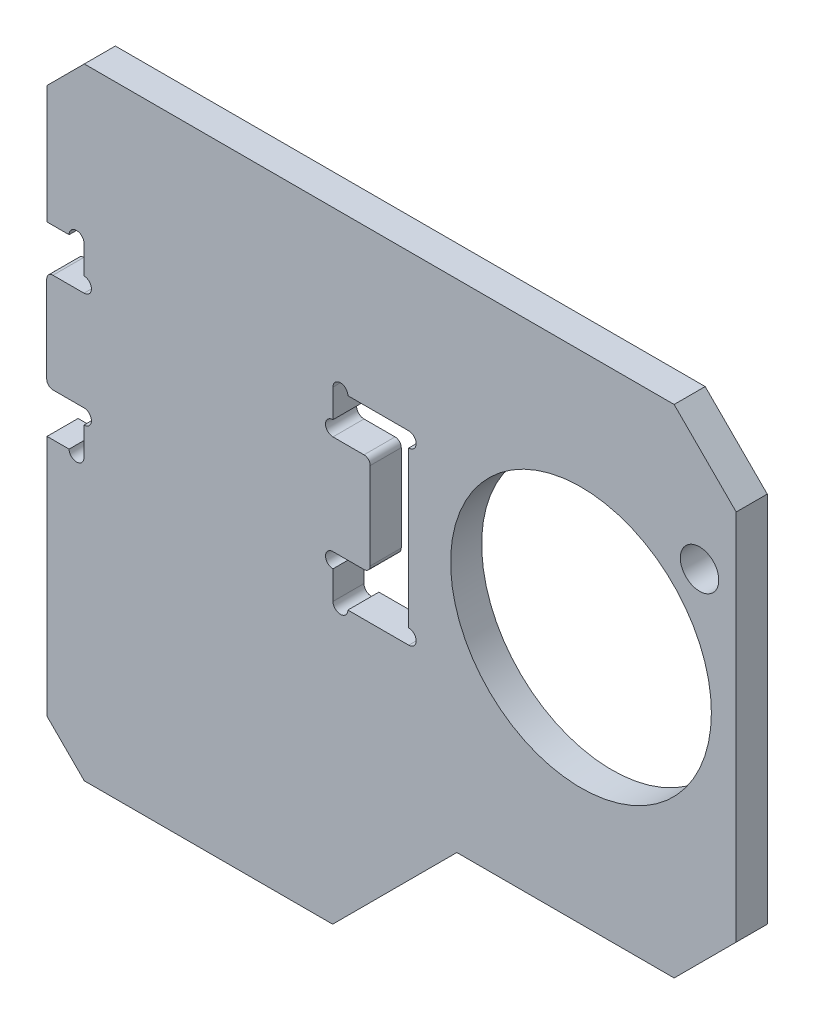
from build123d import *

# Parameters (mm, degrees)
EXTRUDE_1_DEPTH     = 1.25
SKETCH_2_R          = 0.6
CUT_EXTRUDE_1_DEPTH = 3.5
FILLET_1_R          = 0.5
SKETCH_3_R          = 10.5
CUT_EXTRUDE_2_DEPTH = 3.5
CHAMFER_1_SIZE      = 5
CHAMFER_2_SIZE      = 15
CHAMFER_3_SIZE      = 3
CUT_EXTRUDE_4_DEPTH = 3.5
SKETCH_6_R          = 1.55
CUT_EXTRUDE_5_DEPTH = 3.5


with BuildPart() as part:
    # 草图1 → 凸台-拉伸1 (new body, symmetric)
    with BuildSketch(Plane.XY):
        Polygon((-13, 20), (-13, 7.475), (-10.025, 7.475), (-10.025, 4), (-13.025, 4), (-13.025, -4), (-10.025, -4), (-10.025, -7.475), (-13, -7.475), (-13, -30), (42.5, -30), (42.5, 20), align=None)
        Polygon((10.025, 7.475), (10.025, 4), (13.025, 4), (13.025, -4), (10.025, -4), (10.025, -7.475), (16.125, -7.475), (16.125, 7.475), align=None, mode=Mode.SUBTRACT)
    extrude(amount=EXTRUDE_1_DEPTH, both=True)

    # 草图2 → 切除-拉伸1 (cut, through all)
    with BuildSketch(Plane.XY.offset(1.25)):
        with Locations((10.625, 7.475)):
            Circle(SKETCH_2_R)
        with Locations((16.125, 6.875)):
            Circle(SKETCH_2_R)
        with Locations((10.025, 4.6)):
            Circle(SKETCH_2_R)
        with Locations((10.025, -4.6)):
            Circle(SKETCH_2_R)
        with Locations((10.625, -7.475)):
            Circle(SKETCH_2_R)
        with Locations((16.125, -6.875)):
            Circle(SKETCH_2_R)
        with Locations((-10.025, -4.6)):
            Circle(SKETCH_2_R)
        with Locations((-10.625, -7.475)):
            Circle(SKETCH_2_R)
        with Locations((-10.625, 7.475)):
            Circle(SKETCH_2_R)
        with Locations((-10.025, 4.6)):
            Circle(SKETCH_2_R)
    extrude(amount=-CUT_EXTRUDE_1_DEPTH, mode=Mode.SUBTRACT)

    # 圆角1
    fillet_1_edges = [part.edges().sort_by_distance(p)[0] for p in [
        (-13.025, -4, 0),
        (-13.025, 4, 0),
        (13.025, -4, 0),
        (13.025, 4, 0),
    ]]
    fillet(fillet_1_edges, radius=FILLET_1_R)

    # 草图3 → 切除-拉伸2 (cut, through all)
    with BuildSketch(Plane.XY.offset(1.25)):
        with Locations((30, 0)):
            Circle(SKETCH_3_R)
    extrude(amount=-CUT_EXTRUDE_2_DEPTH, mode=Mode.SUBTRACT)

    # 倒角1
    chamfer_1_edges = [part.edges().sort_by_distance(p)[0] for p in [
        (42.5, 20, 0),
    ]]
    chamfer(chamfer_1_edges, length=CHAMFER_1_SIZE)

    # 倒角2
    chamfer_2_edges = [part.edges().sort_by_distance(p)[0] for p in [
        (42.5, -30, 0),
    ]]
    chamfer(chamfer_2_edges, length=CHAMFER_2_SIZE)

    # 倒角3
    chamfer_3_edges = [part.edges().sort_by_distance(p)[0] for p in [
        (-13, -30, 0),
        (-13, 20, 0),
    ]]
    chamfer(chamfer_3_edges, length=CHAMFER_3_SIZE)

    # 草图5 → 切除-拉伸4 (cut, through all)
    with BuildSketch(Plane(origin=(0, 0, -1.25), x_dir=(-1, 0, 0), z_dir=(0, 0, -1))):
        Polygon((-37.5, -20), (-20, -20), (-10, -30), (-27.5, -30), align=None)
    extrude(amount=-CUT_EXTRUDE_4_DEPTH, mode=Mode.SUBTRACT)

    # 草图6 → 切除-拉伸5 (cut, through all)
    with BuildSketch(Plane(origin=(0, 0, -1.25), x_dir=(-1, 0, 0), z_dir=(0, 0, -1))):
        with Locations((-39.545941546, 9.545941546)):
            Circle(SKETCH_6_R)
    extrude(amount=-CUT_EXTRUDE_5_DEPTH, mode=Mode.SUBTRACT)


solid = part.part
